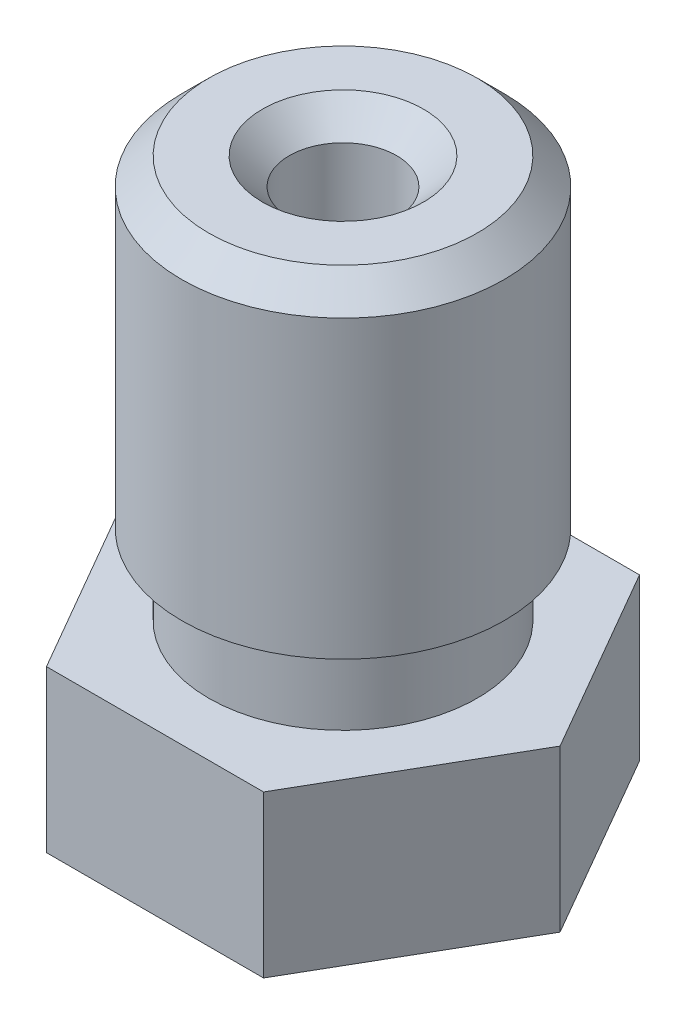
from build123d import *

# Parameters (mm, degrees)
BOSS_EXTRUDE1_DEPTH = 3
CHAMFER1_SIZE       = 0.5


with BuildPart() as part:
    # Sketch1 → Boss-Extrude1 (new body)
    with BuildSketch(Plane.XZ):
        Polygon((2.020725942, -3.5), (4.041451884, 0), (2.020725942, 3.5), (-2.020725942, 3.5), (-4.041451884, 0), (-2.020725942, -3.5), align=None)
    extrude(amount=-BOSS_EXTRUDE1_DEPTH)

    # Sketch2 → Revolve1 (revolve)
    with BuildSketch(Plane(origin=(0, 0, 0), x_dir=(-1, 0, 0), z_dir=(0, 0, -1))):
        Polygon((-2.5, 3), (0, 3), (0, 10.5), (-3, 10.5), (-3, 4.5), (-2.5, 4.5), align=None)
    revolve(axis=Axis((0, 3, 0), (0, 1, 0)))

    # Sketch3 → Revolve2 (revolve)
    with BuildSketch(Plane.XY):
        Polygon((2.5, 0), (0, 0), (0, -2), (0.5, -2), align=None)
    revolve(axis=Axis((0, 0, 0), (0, -1, 0)))

    # Sketch4 → Cut-Revolve1 (revolve, cut)
    with BuildSketch(Plane(origin=(0, 0, 0), x_dir=(-1, 0, 0), z_dir=(0, 0, -1))):
        Polygon((-0.2, -2), (0, -2), (0, 10.5), (-1, 10.5), (-1, 0), (-0.75, -0.227272727), (-0.75, -0.7), (-0.2, -1.2), align=None)
    revolve(axis=Axis((0, -2, 0), (0, 1, 0)), mode=Mode.SUBTRACT)

    # Chamfer1
    chamfer1_edges = [part.edges().sort_by_distance(p)[0] for p in [
        (-3, 10.5, 0),
        (-1, 10.5, 0),
    ]]
    chamfer(chamfer1_edges, length=CHAMFER1_SIZE)


solid = part.part
